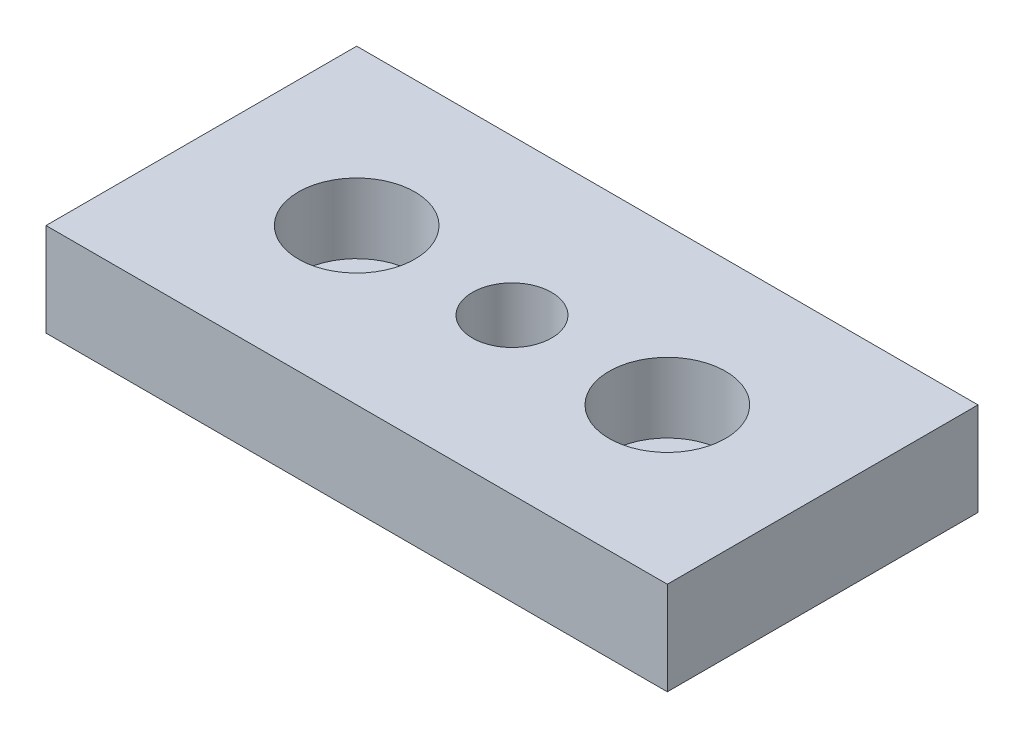
from build123d import *

# Parameters (mm, degrees)
SKETCH_1_W             = 80
SKETCH_1_H             = 40
EXTRUDE_1_DEPTH        = 12
HOLE_WIZARD_M121_D     = 10.2
HOLE_WIZARD_M121_DEPTH = 12


with BuildPart() as part:
    # Эскиз1 → Бобышка-Вытянуть1 (new body)
    with BuildSketch(Plane(origin=(0, 0, 0), x_dir=(1, 0, 0), z_dir=(0, 1, 0))):
        Rectangle(SKETCH_1_W, SKETCH_1_H)
    extrude(amount=EXTRUDE_1_DEPTH)

    # Эскиз2 → Вырез-Повернуть1 (revolve, cut)
    with BuildSketch(Plane.XY):
        Polygon((-27.5, 12), (-27.5, 3), (-24.5, 3), (-24.5, 0), (-20, 0), (-20, 12), align=None)
    cut_revolve_1 = revolve(axis=Axis((-20, 12, 0), (0, -1, 0)), mode=Mode.SUBTRACT)

    # Зеркальное отражение1: Вырез-Повернуть1 across plane
    add(cut_revolve_1.mirror(Plane(origin=(0, 0, 0), x_dir=(0, 0, 1), z_dir=(1, 0, 0))), mode=Mode.SUBTRACT)

    # Отверстие обработанное метчиком M121
    with Locations(Plane(origin=(0, 12, 0), x_dir=(1, 0, 0), z_dir=(0, 1, 0))):
        with Locations((0, 0)):
            Hole(HOLE_WIZARD_M121_D / 2, depth=HOLE_WIZARD_M121_DEPTH)


solid = part.part
